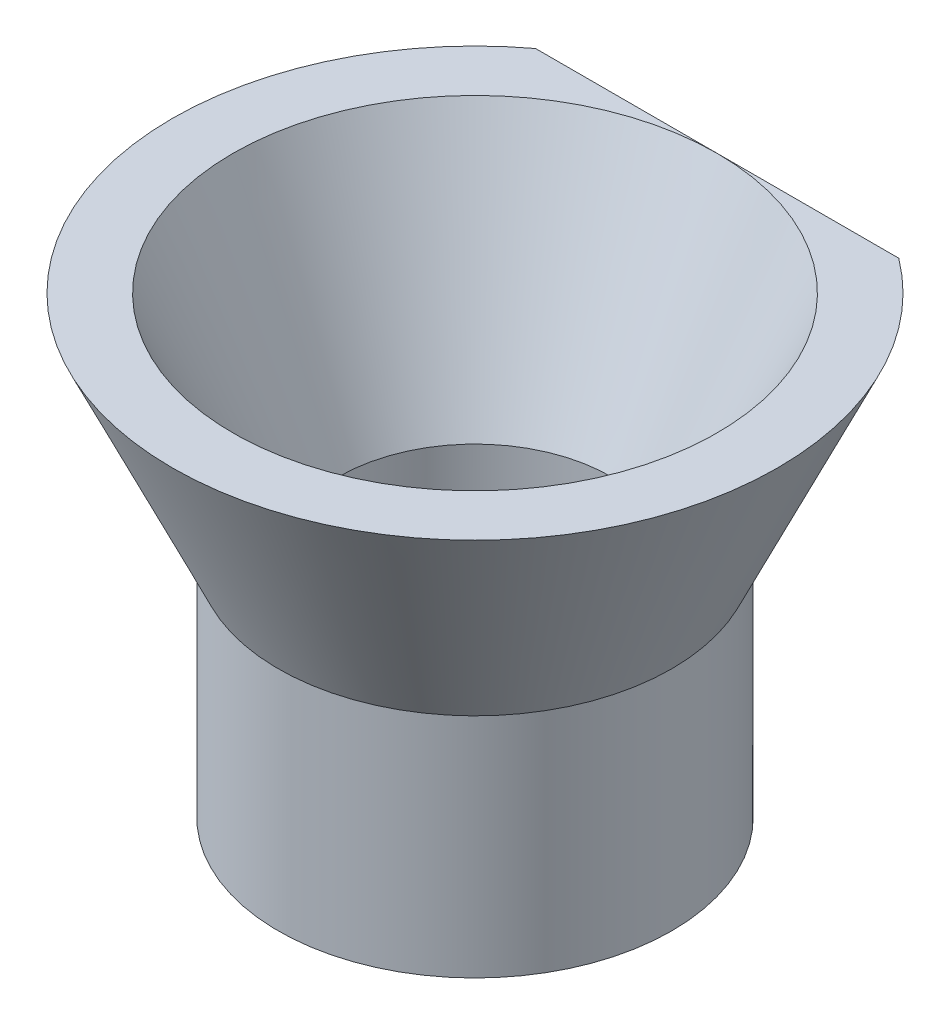
from build123d import *

# Parameters (mm, degrees)
CROQUIS3_R              = 6.5
CROQUIS3_R_2            = 4.5
SALIENTE_EXTRUIR1_DEPTH = 7.5
CORTAR_EXTRUIR1_DEPTH   = 7.5


with BuildPart() as part:
    # Croquis2 → Revolución1 (revolve)
    with BuildSketch(Plane.XY):
        Polygon((-4.5, 0), (-8, 7.5), (-10, 7.5), (-6.5, 0), align=None)
    revolve(axis=Axis((0, 7.5, 0), (0, -1, 0)))

    # Croquis3 → Saliente-Extruir1 (add)
    with BuildSketch(Plane.XZ):
        Circle(CROQUIS3_R)
        Circle(CROQUIS3_R_2, mode=Mode.SUBTRACT)
    extrude(amount=SALIENTE_EXTRUIR1_DEPTH)

    # Croquis4 → Cortar-Extruir1 (cut)
    with BuildSketch(Plane(origin=(0, 7.5, 0), x_dir=(1, 0, 0), z_dir=(0, 1, 0))):
        Polygon((-9.027753826, 8), (9.027753826, 8), (9.027753826, 15.356589522), (-9.467057566, 15.356589522), align=None)
    extrude(amount=-CORTAR_EXTRUIR1_DEPTH, mode=Mode.SUBTRACT)


solid = part.part
